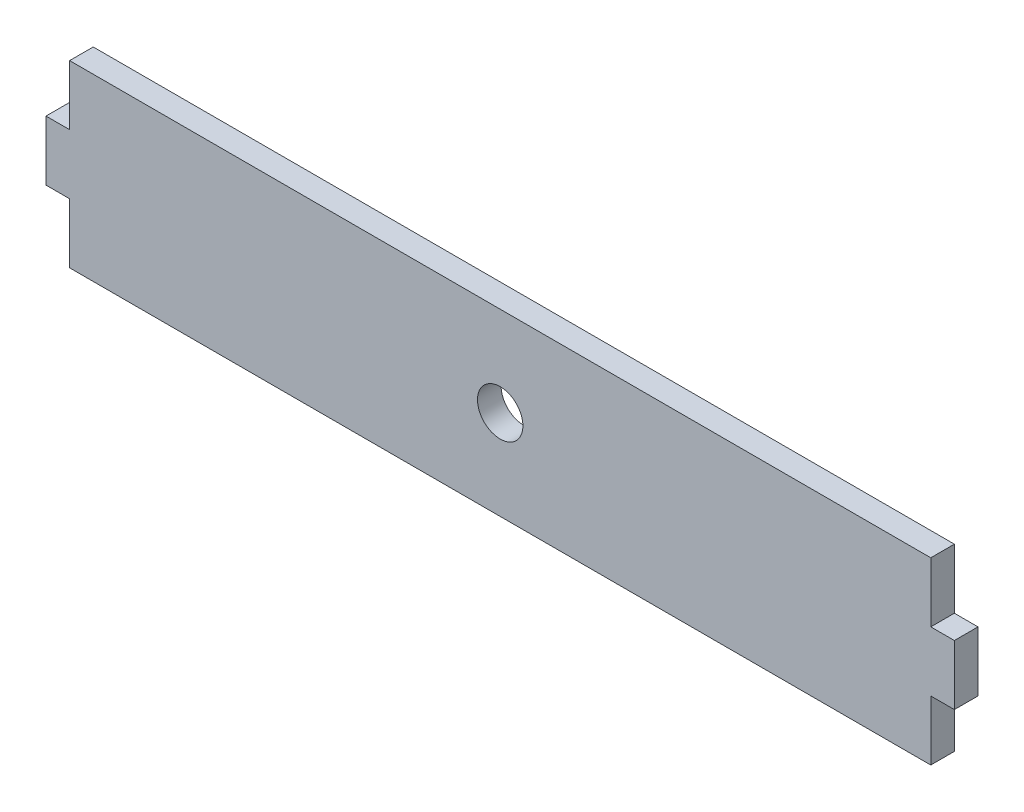
from build123d import *

# Parameters (mm, degrees)
SKETCH1_R           = 2.5
BOSS_EXTRUDE1_DEPTH = 2.6


with BuildPart() as part:
    # Sketch1 → Boss-Extrude1 (new body)
    with BuildSketch(Plane.XY):
        Polygon((2.6, -1.162405209), (97.4, -1.162405209), (97.4, 5.424557644), (100, 5.424557644), (100, 12.011520496), (97.4, 12.011520496), (97.4, 18.598483349), (2.6, 18.598483349), (2.6, 12.011520496), (0, 12.011520496), (0, 5.424557644), (2.6, 5.424557644), align=None)
        with Locations((50, 8.71803907)):
            Circle(SKETCH1_R, mode=Mode.SUBTRACT)
    extrude(amount=BOSS_EXTRUDE1_DEPTH)


solid = part.part
